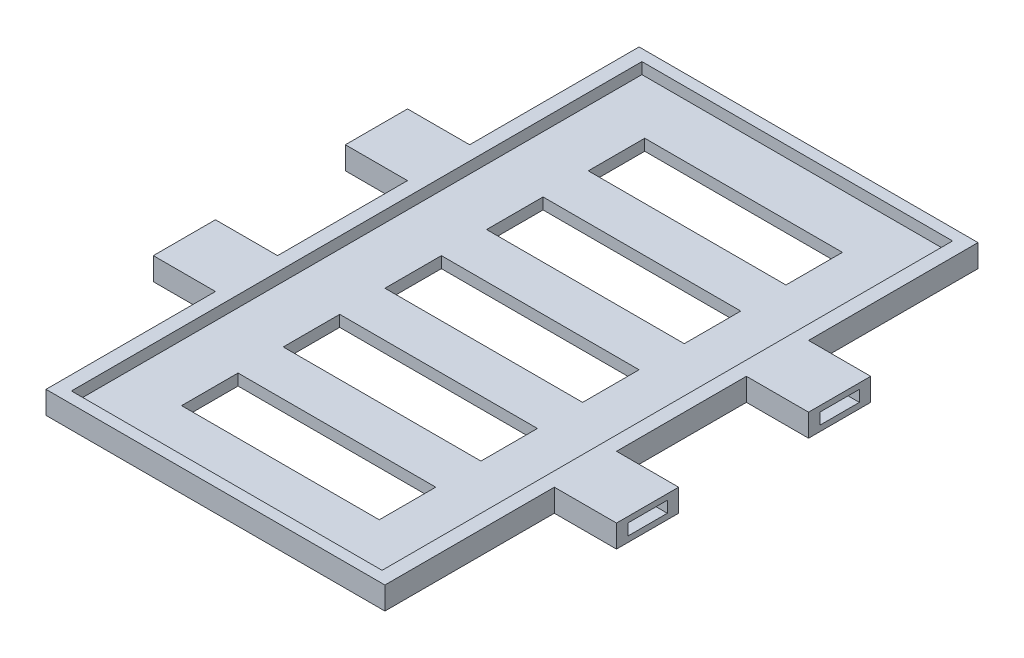
from build123d import *

# Parameters (mm, degrees)
SALIENTE_EXTRUIR1_DEPTH = 4
CROQUIS2_W              = 55
CROQUIS2_H              = 101
CORTAR_EXTRUIR1_DEPTH   = 2
CROQUIS4_W              = 7
CROQUIS4_H              = 2
CORTAR_EXTRUIR2_DEPTH   = 9
CROQUIS6_W              = 7
CROQUIS6_H              = 2
CORTAR_EXTRUIR3_DEPTH   = 9
CROQUIS7_W              = 7
CROQUIS7_H              = 2
CORTAR_EXTRUIR4_DEPTH   = 9
CROQUIS8_W              = 7
CROQUIS8_H              = 2
CORTAR_EXTRUIR5_DEPTH   = 9
CROQUIS10_W             = 35
CROQUIS10_H             = 10
CORTAR_EXTRUIR6_DEPTH   = 5


with BuildPart() as part:
    # Croquis1 → Saliente-Extruir1 (new body)
    with BuildSketch(Plane(origin=(0, 0, 0), x_dir=(1, 0, 0), z_dir=(0, 1, 0))):
        Polygon((30, -52.5), (30, -22.5), (41, -22.5), (41, -11.5), (30, -11.5), (30, 11.5), (41, 11.5), (41, 22.5), (30, 22.5), (30, 52.5), (-30, 52.5), (-30, 22.5), (-41, 22.5), (-41, 11.5), (-30, 11.5), (-30, -11.5), (-41, -11.5), (-41, -22.5), (-30, -22.5), (-30, -52.5), align=None)
    extrude(amount=SALIENTE_EXTRUIR1_DEPTH)

    # Croquis2 → Cortar-Extruir1 (cut)
    with BuildSketch(Plane(origin=(0, 4, 0), x_dir=(1, 0, 0), z_dir=(0, 1, 0))):
        Rectangle(CROQUIS2_W, CROQUIS2_H)
    extrude(amount=-CORTAR_EXTRUIR1_DEPTH, mode=Mode.SUBTRACT)

    # Croquis4 → Cortar-Extruir2 (cut)
    with BuildSketch(Plane.ZY.offset(41)):
        with Locations((-17, 2)):
            Rectangle(CROQUIS4_W, CROQUIS4_H)
    extrude(amount=-CORTAR_EXTRUIR2_DEPTH, mode=Mode.SUBTRACT)

    # Croquis6 → Cortar-Extruir3 (cut)
    with BuildSketch(Plane.ZY.offset(41)):
        with Locations((17, 2)):
            Rectangle(CROQUIS6_W, CROQUIS6_H)
    extrude(amount=-CORTAR_EXTRUIR3_DEPTH, mode=Mode.SUBTRACT)

    # Croquis7 → Cortar-Extruir4 (cut)
    with BuildSketch(Plane(origin=(41, 0, 0), x_dir=(0, 0, -1), z_dir=(1, 0, 0))):
        with Locations((-17, 2)):
            Rectangle(CROQUIS7_W, CROQUIS7_H)
    extrude(amount=-CORTAR_EXTRUIR4_DEPTH, mode=Mode.SUBTRACT)

    # Croquis8 → Cortar-Extruir5 (cut)
    with BuildSketch(Plane(origin=(41, 0, 0), x_dir=(0, 0, -1), z_dir=(1, 0, 0))):
        with Locations((17, 2)):
            Rectangle(CROQUIS8_W, CROQUIS8_H)
    extrude(amount=-CORTAR_EXTRUIR5_DEPTH, mode=Mode.SUBTRACT)

    # Croquis10 → Cortar-Extruir6 (cut, through all)
    with BuildSketch(Plane(origin=(0, 0, 0), x_dir=(1, 0, 0), z_dir=(0, 1, 0))):
        with Locations((0, 36)):
            Rectangle(CROQUIS10_W, CROQUIS10_H)
        with Locations((0, 18)):
            Rectangle(CROQUIS10_W, CROQUIS10_H)
        Rectangle(CROQUIS10_W, CROQUIS10_H)
        with Locations((0, -18)):
            Rectangle(CROQUIS10_W, CROQUIS10_H)
        with Locations((0, -36)):
            Rectangle(CROQUIS10_W, CROQUIS10_H)
    extrude(amount=CORTAR_EXTRUIR6_DEPTH, mode=Mode.SUBTRACT)


solid = part.part
